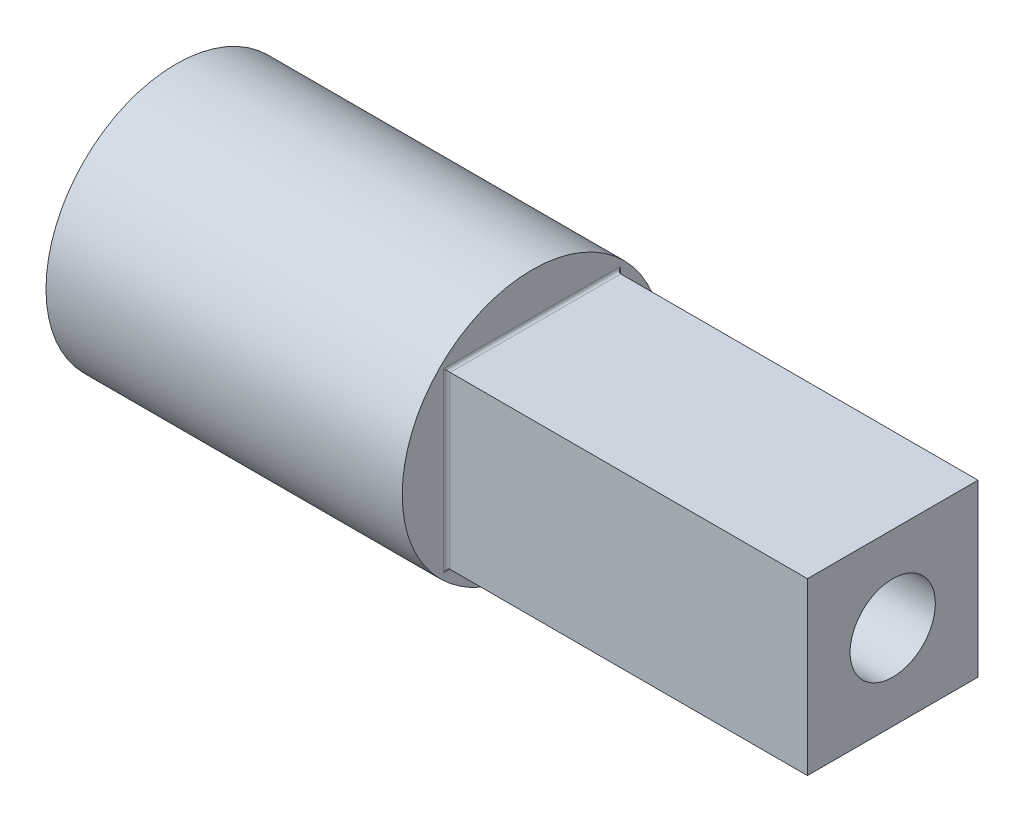
from build123d import *

# Parameters (mm, degrees)
SKETCH1_R           = 32
BOSS_EXTRUDE1_DEPTH = 87.72
SKETCH2_W           = 42
SKETCH2_H           = 42
BOSS_EXTRUDE2_DEPTH = 88.78
FILLET2_R           = 0.8
SKETCH3_R           = 10.5
CUT_EXTRUDE1_DEPTH  = 16


with BuildPart() as part:
    # Sketch1 → Boss-Extrude1 (new body)
    with BuildSketch(Plane(origin=(0, 0, 0), x_dir=(0, 0, -1), z_dir=(1, 0, 0))):
        Circle(SKETCH1_R)
    extrude(amount=BOSS_EXTRUDE1_DEPTH)

    # Sketch2 → Boss-Extrude2 (add)
    with BuildSketch(Plane(origin=(87.72, 0, 0), x_dir=(0, 0, -1), z_dir=(1, 0, 0))):
        Rectangle(SKETCH2_W, SKETCH2_H)
    extrude(amount=BOSS_EXTRUDE2_DEPTH)

    # Fillet2
    fillet2_edges = [part.edges().sort_by_distance(p)[0] for p in [
        (87.72, -21, 0),
        (87.72, 0, -21),
        (87.72, 21, 0),
        (87.72, 0, 21),
    ]]
    fillet(fillet2_edges, radius=FILLET2_R)

    # Sketch3 → Cut-Extrude1 (cut)
    with BuildSketch(Plane(origin=(176.5, 0, 0), x_dir=(0, 0, -1), z_dir=(1, 0, 0))):
        Circle(SKETCH3_R)
    extrude(amount=-CUT_EXTRUDE1_DEPTH, mode=Mode.SUBTRACT)


solid = part.part
